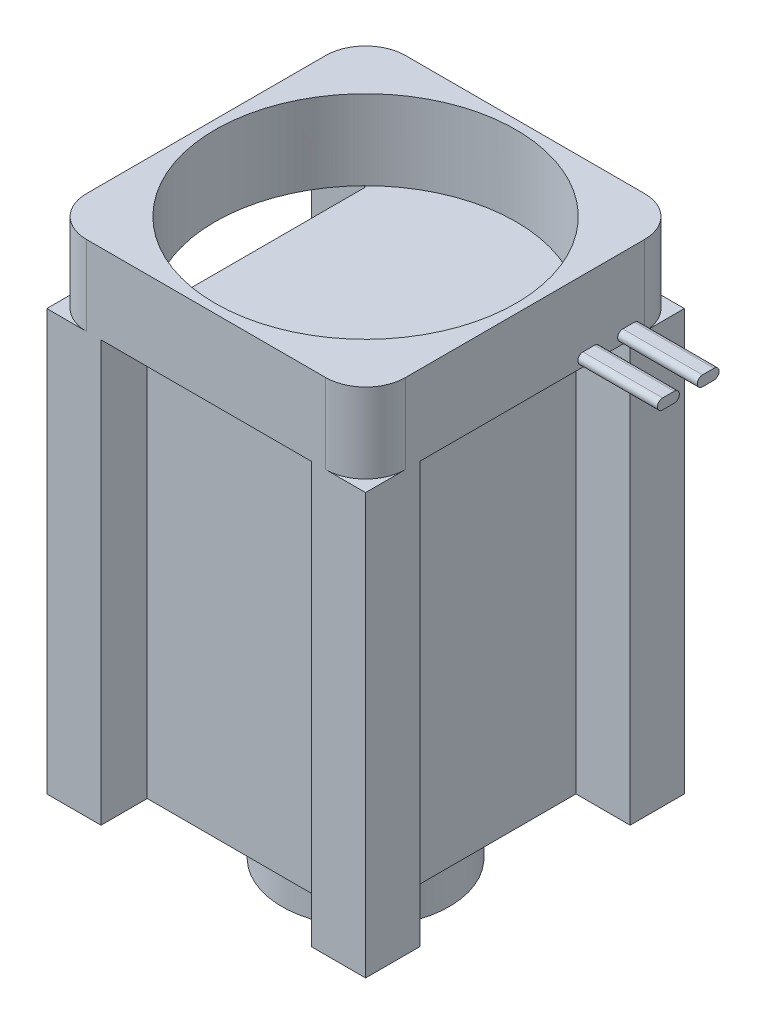
from build123d import *

# Parameters (mm, degrees)
SKETCH1_W                 = 40
SKETCH1_H                 = 40
BOSS_EXTRUDE1_DEPTH       = 62.75
SKETCH2_R                 = 18.875
CUT_EXTRUDE1_DEPTH        = 10
SKETCH4_R                 = 10.5
BOSS_EXTRUDE2_DEPTH       = 7
SKETCH5_W                 = 26.4
SKETCH5_H                 = 5.8
SKETCH5_W_2               = 6.8
SKETCH5_H_2               = 26.4
CUT_EXTRUDE2_DEPTH        = 52.75
M3X0_5_TAPPED_HOLE1_D     = 2.5
M3X0_5_TAPPED_HOLE1_DEPTH = 5
M3X0_5_TAPPED_HOLE1_TIP   = 0.751075774
BOSS_EXTRUDE3_DEPTH       = 10


with BuildPart() as part:
    # Sketch1 → Boss-Extrude1 (new body)
    with BuildSketch(Plane(origin=(0, 0, 0), x_dir=(1, 0, 0), z_dir=(0, 1, 0))):
        Rectangle(SKETCH1_W, SKETCH1_H)
    extrude(amount=BOSS_EXTRUDE1_DEPTH)

    # Sketch2 → Cut-Extrude1 (cut)
    with BuildSketch(Plane(origin=(0, 62.75, 0), x_dir=(1, 0, 0), z_dir=(0, 1, 0))):
        Circle(SKETCH2_R)
        with BuildLine():
            ThreePointArc((-15, -20), (-18.535533906, -18.535533906), (-20, -15))
            Line((-20, -15), (-20, -20))
            Line((-20, -20), (-15, -20))
        make_face()
        with BuildLine():
            ThreePointArc((20, -15), (18.535533906, -18.535533906), (15, -20))
            Line((15, -20), (20, -20))
            Line((20, -20), (20, -15))
        make_face()
        with BuildLine():
            Line((20, 20), (15, 20))
            ThreePointArc((15, 20), (18.535533906, 18.535533906), (20, 15))
            Line((20, 15), (20, 20))
        make_face()
        with BuildLine():
            Line((-15, 20), (-20, 20))
            Line((-20, 20), (-20, 15))
            ThreePointArc((-20, 15), (-18.535533906, 18.535533906), (-15, 20))
        make_face()
    extrude(amount=-CUT_EXTRUDE1_DEPTH, mode=Mode.SUBTRACT)

    # Sketch4 → Boss-Extrude2 (add)
    with BuildSketch(Plane.XZ):
        Circle(SKETCH4_R)
    extrude(amount=BOSS_EXTRUDE2_DEPTH)

    # Sketch5 → Cut-Extrude2 (cut)
    with BuildSketch(Plane.XZ):
        with Locations((0, 17.1)):
            Rectangle(SKETCH5_W, SKETCH5_H)
        with Locations((16.6, 0)):
            Rectangle(SKETCH5_W_2, SKETCH5_H_2)
        with Locations((-16.6, 0)):
            Rectangle(SKETCH5_W_2, SKETCH5_H_2)
    extrude(amount=-CUT_EXTRUDE2_DEPTH, mode=Mode.SUBTRACT)

    # M3x0.5 Tapped Hole1
    with Locations(Plane(origin=(0, 0, -20), x_dir=(-1, 0, 0), z_dir=(0, 0, -1))):
        with Locations((-10, 45), (10, 45), (10, 5), (-10, 5), (0, 35)):
            Hole(M3X0_5_TAPPED_HOLE1_D / 2, depth=M3X0_5_TAPPED_HOLE1_DEPTH)
            with Locations((0, 0, -(M3X0_5_TAPPED_HOLE1_DEPTH + M3X0_5_TAPPED_HOLE1_TIP / 2))):  # 118° drill point
                Cone(0, M3X0_5_TAPPED_HOLE1_D / 2, M3X0_5_TAPPED_HOLE1_TIP, mode=Mode.SUBTRACT)

    # Sketch9 → Boss-Extrude3 (add)
    with BuildSketch(Plane(origin=(20, 0, 0), x_dir=(0, 0, -1), z_dir=(1, 0, 0))):
        with BuildLine():
            Line((7.275, 54.4), (8.725, 54.4))
            ThreePointArc((8.725, 54.4), (9.375, 53.75), (8.725, 53.1))
            Line((8.725, 53.1), (7.275, 53.1))
            ThreePointArc((7.275, 53.1), (6.625, 53.75), (7.275, 54.4))
        make_face()
        with BuildLine():
            Line((12.275, 54.4), (13.725, 54.4))
            ThreePointArc((13.725, 54.4), (14.375, 53.75), (13.725, 53.1))
            Line((13.725, 53.1), (12.275, 53.1))
            ThreePointArc((12.275, 53.1), (11.625, 53.75), (12.275, 54.4))
        make_face()
    extrude(amount=BOSS_EXTRUDE3_DEPTH)


solid = part.part
